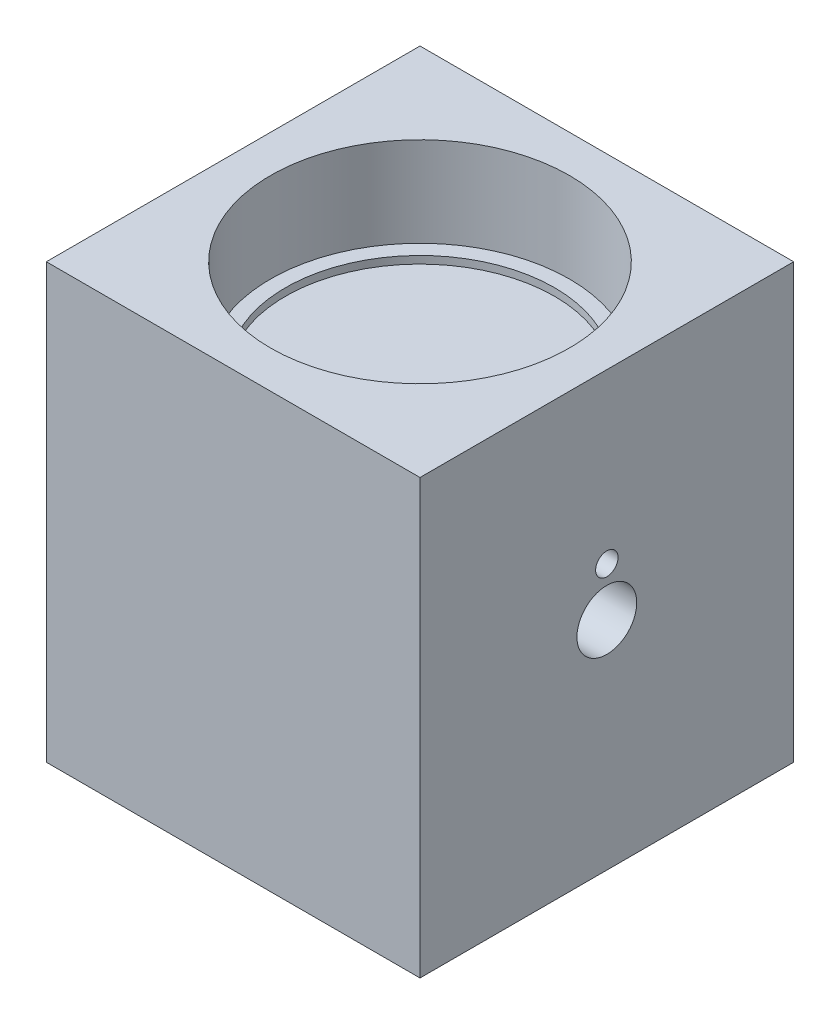
from build123d import *

# Parameters (mm, degrees)
SKETCH1_W           = 50
SKETCH1_H           = 50
BOSS_EXTRUDE1_DEPTH = 29
SKETCH2_R           = 10
CUT_EXTRUDE1_DEPTH  = 40
SKETCH5_R           = 1.5
SKETCH5_R_2         = 4
CUT_EXTRUDE2_DEPTH  = 11
SKETCH6_R           = 20
CUT_EXTRUDE3_DEPTH  = 12
SKETCH7_R           = 18
CUT_EXTRUDE4_DEPTH  = 1


with BuildPart() as part:
    # Sketch1 → Boss-Extrude1 (new body, symmetric)
    with BuildSketch(Plane(origin=(0, 0, 0), x_dir=(1, 0, 0), z_dir=(0, 1, 0))):
        Rectangle(SKETCH1_W, SKETCH1_H)
    extrude(amount=BOSS_EXTRUDE1_DEPTH, both=True)

    # Sketch2 → Cut-Extrude1 (cut)
    with BuildSketch(Plane.ZY.offset(25)):
        Circle(SKETCH2_R)
    extrude(amount=-CUT_EXTRUDE1_DEPTH, mode=Mode.SUBTRACT)

    # Sketch5 → Cut-Extrude2 (cut, through all)
    with BuildSketch(Plane.ZY.offset(-15)):
        with Locations((0, 6.5)):
            Circle(SKETCH5_R)
        Circle(SKETCH5_R_2)
    extrude(amount=-CUT_EXTRUDE2_DEPTH, mode=Mode.SUBTRACT)

    # Sketch6 → Cut-Extrude3 (cut)
    with BuildSketch(Plane(origin=(0, 29, 0), x_dir=(1, 0, 0), z_dir=(0, 1, 0))):
        Circle(SKETCH6_R)
    cut_extrude3 = extrude(amount=-CUT_EXTRUDE3_DEPTH, mode=Mode.SUBTRACT)

    # Sketch7 → Cut-Extrude4 (cut)
    with BuildSketch(Plane(origin=(0, 17, 0), x_dir=(1, 0, 0), z_dir=(0, 1, 0))):
        Circle(SKETCH7_R)
    cut_extrude4 = extrude(amount=-CUT_EXTRUDE4_DEPTH, mode=Mode.SUBTRACT)

    # Mirror1: Cut-Extrude3, Cut-Extrude4 across plane
    add(cut_extrude3.mirror(Plane.ZX), mode=Mode.SUBTRACT)
    add(cut_extrude4.mirror(Plane.ZX), mode=Mode.SUBTRACT)


solid = part.part
